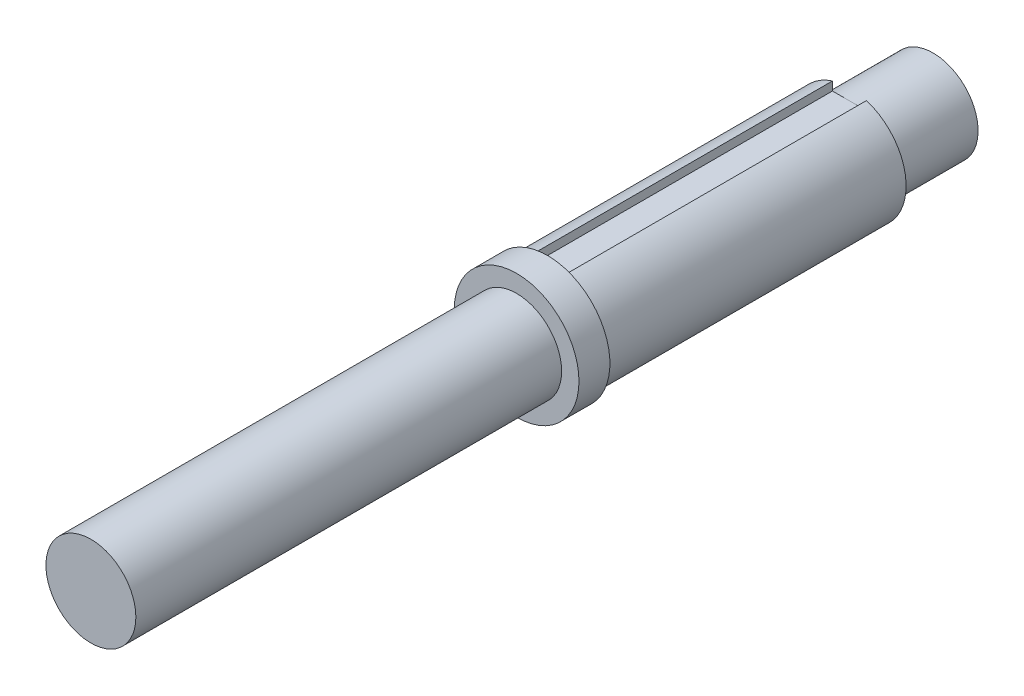
from build123d import *

# Parameters (mm, degrees)
SKETCH1_R           = 5.5
BOSS_EXTRUDE1_DEPTH = 160.3
SKETCH3_OUTSIDE_W   = 45.21
SKETCH3_OUTSIDE_H   = 45.21
SKETCH3_OUTSIDE_R   = 5
CUT_EXTRUDE2_DEPTH  = 120
SKETCH4_OUTSIDE_W   = 45.21
SKETCH4_OUTSIDE_H   = 45.21
SKETCH4_OUTSIDE_R   = 3.96875
CUT_EXTRUDE3_DEPTH  = 37.57
SKETCH5_OUTSIDE_W   = 45.21
SKETCH5_OUTSIDE_H   = 45.21
SKETCH5_OUTSIDE_R   = 3.97
CUT_EXTRUDE4_DEPTH  = 93.36
SKETCH9_W           = 3
SKETCH9_H           = 27
CUT_EXTRUDE6_DEPTH  = 1
SKETCH11_W          = 3.767354336
SKETCH11_H          = 27
CUT_EXTRUDE7_DEPTH  = 1
SKETCH12_R          = 15.914705016
CUT_EXTRUDE8_DEPTH  = 85.98


with BuildPart() as part:
    # Sketch1 → Boss-Extrude1 (new body)
    with BuildSketch(Plane.XY):
        Circle(SKETCH1_R)
    extrude(amount=BOSS_EXTRUDE1_DEPTH)

    # Sketch3 outside → Cut-Extrude2 (cut)
    with BuildSketch(Plane(origin=(0, 0, 0), x_dir=(-1, 0, 0), z_dir=(0, 0, -1))):
        Rectangle(SKETCH3_OUTSIDE_W, SKETCH3_OUTSIDE_H)
        Circle(SKETCH3_OUTSIDE_R, mode=Mode.SUBTRACT)
    extrude(amount=-CUT_EXTRUDE2_DEPTH, mode=Mode.SUBTRACT)

    # Sketch4 outside → Cut-Extrude3 (cut)
    with BuildSketch(Plane.XY.offset(160.3)):
        Rectangle(SKETCH4_OUTSIDE_W, SKETCH4_OUTSIDE_H)
        Circle(SKETCH4_OUTSIDE_R, mode=Mode.SUBTRACT)
    extrude(amount=-CUT_EXTRUDE3_DEPTH, mode=Mode.SUBTRACT)

    # Sketch5 outside → Cut-Extrude4 (cut)
    with BuildSketch(Plane(origin=(0, 0, 0), x_dir=(-1, 0, 0), z_dir=(0, 0, -1))):
        Rectangle(SKETCH5_OUTSIDE_W, SKETCH5_OUTSIDE_H)
        Circle(SKETCH5_OUTSIDE_R, mode=Mode.SUBTRACT)
    extrude(amount=-CUT_EXTRUDE4_DEPTH, mode=Mode.SUBTRACT)

    # Sketch9 → Cut-Extrude6 (cut)
    with BuildSketch(Plane(origin=(0, 5, 0), x_dir=(1, 0, 0), z_dir=(0, 1, 0))):
        with Locations((0, -106.5)):
            Rectangle(SKETCH9_W, SKETCH9_H)
    extrude(amount=-CUT_EXTRUDE6_DEPTH, mode=Mode.SUBTRACT)

    # Sketch11 → Cut-Extrude7 (cut)
    with BuildSketch(Plane(origin=(0, -5, 0), x_dir=(-1, 0, 0), z_dir=(0, -1, 0))):
        with Locations((0, -106.520343873)):
            Rectangle(SKETCH11_W, SKETCH11_H)
    extrude(amount=-CUT_EXTRUDE7_DEPTH, mode=Mode.SUBTRACT)

    # Sketch12 → Cut-Extrude8 (cut)
    with BuildSketch(Plane(origin=(0, 0, 0), x_dir=(-1, 0, 0), z_dir=(0, 0, -1))):
        Circle(SKETCH12_R)
    extrude(amount=-CUT_EXTRUDE8_DEPTH, mode=Mode.SUBTRACT)


solid = part.part
